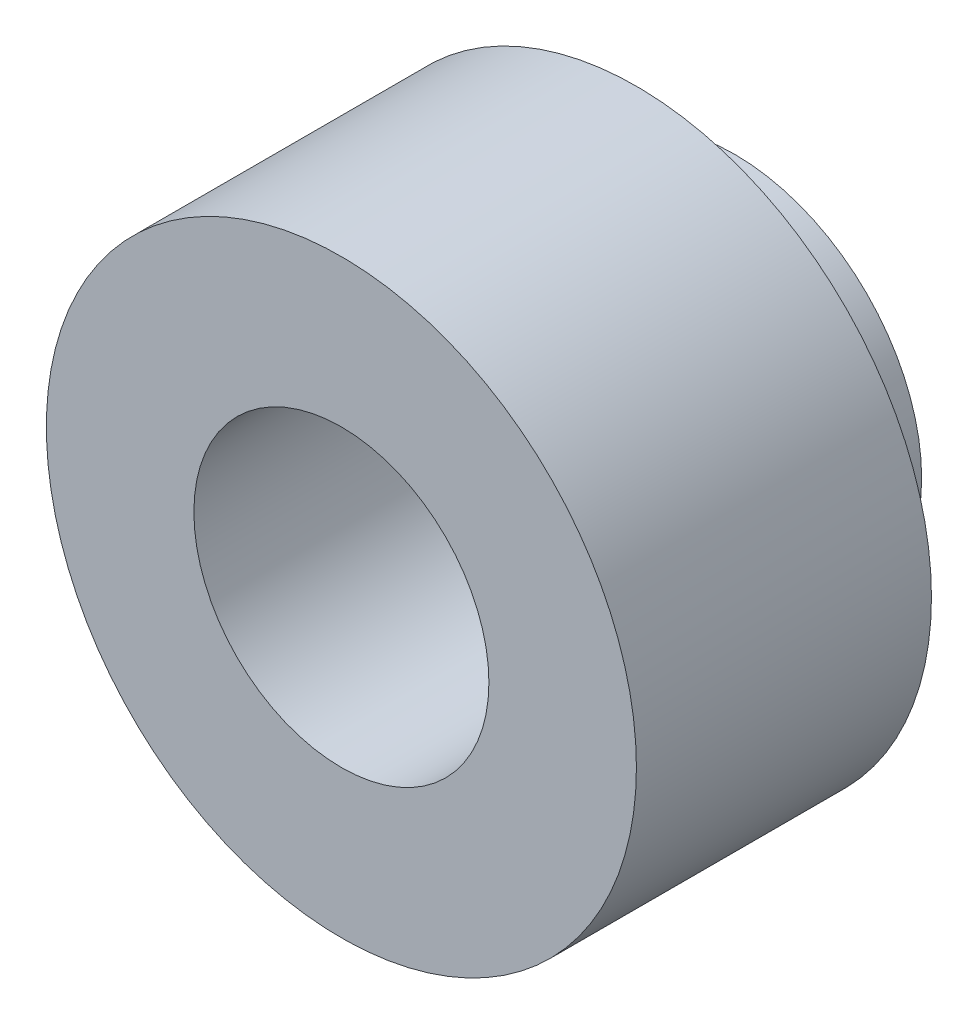
from build123d import *

# Parameters (mm, degrees)
SKETCH1_R           = 3.75
SKETCH1_R_2         = 1.875
BOSS_EXTRUDE1_DEPTH = 3.75
SKETCH2_R           = 2.375
SKETCH2_R_2         = 1.875
BOSS_EXTRUDE2_DEPTH = 1.25


with BuildPart() as part:
    # Sketch1 → Boss-Extrude1 (new body)
    with BuildSketch(Plane.XY):
        Circle(SKETCH1_R)
        Circle(SKETCH1_R_2, mode=Mode.SUBTRACT)
    extrude(amount=BOSS_EXTRUDE1_DEPTH)

    # Sketch2 → Boss-Extrude2 (add)
    with BuildSketch(Plane(origin=(0, 0, 0), x_dir=(-1, 0, 0), z_dir=(0, 0, -1))):
        Circle(SKETCH2_R)
        Circle(SKETCH2_R_2, mode=Mode.SUBTRACT)
    extrude(amount=BOSS_EXTRUDE2_DEPTH)


solid = part.part
